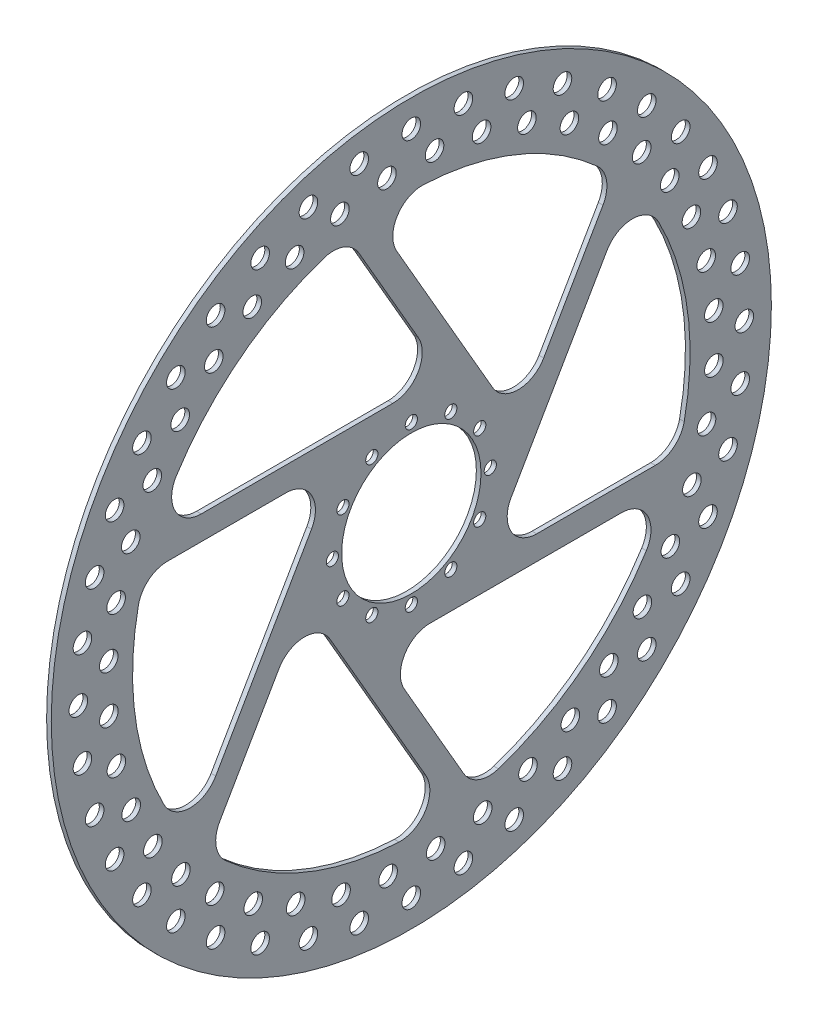
from build123d import *

# Parameters (mm, degrees)
SKETCH1_R           = 155
SKETCH1_R_2         = 4
SKETCH1_R_3         = 2.625
SKETCH1_R_4         = 30
BOSS_EXTRUDE1_DEPTH = 2
FILLET1_R           = 12.7


with BuildPart() as part:
    # Sketch1 → Boss-Extrude1 (new body)
    with BuildSketch(Plane(origin=(0, 0, 0), x_dir=(0, 0, -1), z_dir=(1, 0, 0))):
        Circle(SKETCH1_R)
        with BuildLine():
            Line((-27.462565886, 116.815270727), (14, 45))
            Line((14, 45), (-111.242977306, 45))
            ThreePointArc((-111.242977306, 45), (-78.097152352, 91.108917206), (-27.462565886, 116.815270727))
        make_face(mode=Mode.SUBTRACT)
        with BuildLine():
            Line((45.97114317, 10.375644347), (-16.650345483, 118.83924434))
            ThreePointArc((-16.650345483, 118.83924434), (39.854060636, 113.188576503), (87.433709056, 82.190915074))
            Line((87.433709056, 82.190915074), (45.97114317, 10.375644347))
        make_face(mode=Mode.SUBTRACT)
        with BuildLine():
            Line((31.97114317, -34.624355653), (94.592631824, 73.83924434))
            ThreePointArc((94.592631824, 73.83924434), (117.951212988, 22.079659297), (114.896274942, -34.624355653))
            Line((114.896274942, -34.624355653), (31.97114317, -34.624355653))
        make_face(mode=Mode.SUBTRACT)
        with BuildLine():
            Line((-14, -45), (111.242977306, -45))
            ThreePointArc((111.242977306, -45), (78.097152352, -91.108917206), (27.462565886, -116.815270727))
            Line((27.462565886, -116.815270727), (-14, -45))
        make_face(mode=Mode.SUBTRACT)
        with BuildLine():
            Line((-45.97114317, -10.375644347), (16.650345483, -118.83924434))
            ThreePointArc((16.650345483, -118.83924434), (-39.854060636, -113.188576503), (-87.433709056, -82.190915074))
            Line((-87.433709056, -82.190915074), (-45.97114317, -10.375644347))
        make_face(mode=Mode.SUBTRACT)
        with BuildLine():
            Line((-31.97114317, 34.624355653), (-94.592631824, -73.83924434))
            ThreePointArc((-94.592631824, -73.83924434), (-117.951212988, -22.079659297), (-114.896274942, 34.624355653))
            Line((-114.896274942, 34.624355653), (-31.97114317, 34.624355653))
        make_face(mode=Mode.SUBTRACT)
        with Locations((-101.35197197, -101.35197197)):
            Circle(SKETCH1_R_2, mode=Mode.SUBTRACT)
        with Locations((-84.249219495, -115.959102527)):
            Circle(SKETCH1_R_2, mode=Mode.SUBTRACT)
        with Locations((-84.643406638, -99.488638417)):
            Circle(SKETCH1_R_2, mode=Mode.SUBTRACT)
        with Locations((-115.959102527, -84.249219495)):
            Circle(SKETCH1_R_2, mode=Mode.SUBTRACT)
        with Locations((-99.164757773, -85.022622149)):
            Circle(SKETCH1_R_2, mode=Mode.SUBTRACT)
        with Locations((-44.29243586, -136.318100669)):
            Circle(SKETCH1_R_2, mode=Mode.SUBTRACT)
        with Locations((-65.071971629, -127.710935134)):
            Circle(SKETCH1_R_2, mode=Mode.SUBTRACT)
        with Locations((-49.756983427, -120.775568977)):
            Circle(SKETCH1_R_2, mode=Mode.SUBTRACT)
        with Locations((-22.422273322, -141.568662152)):
            Circle(SKETCH1_R_2, mode=Mode.SUBTRACT)
        with Locations((0, -143.333333333)):
            Circle(SKETCH1_R_2, mode=Mode.SUBTRACT)
        with Locations((-30.250930871, -127.072328391)):
            Circle(SKETCH1_R_2, mode=Mode.SUBTRACT)
        with Locations((-10, -130.240145352)):
            Circle(SKETCH1_R_2, mode=Mode.SUBTRACT)
        with Locations((-68.037853917, -111.504914223)):
            Circle(SKETCH1_R_2, mode=Mode.SUBTRACT)
        with Locations((-127.710935134, -65.071971629)):
            Circle(SKETCH1_R_2, mode=Mode.SUBTRACT)
        with Locations((-136.318100669, -44.29243586)):
            Circle(SKETCH1_R_2, mode=Mode.SUBTRACT)
        with Locations((-120.584724218, -50.217723433)):
            Circle(SKETCH1_R_2, mode=Mode.SUBTRACT)
        with Locations((-111.244343463, -68.463066751)):
            Circle(SKETCH1_R_2, mode=Mode.SUBTRACT)
        with Locations((-141.568662152, -22.422273322)):
            Circle(SKETCH1_R_2, mode=Mode.SUBTRACT)
        with Locations((-126.955908864, -30.735853101)):
            Circle(SKETCH1_R_2, mode=Mode.SUBTRACT)
        with Locations((-130.201017692, -10.497164059)):
            Circle(SKETCH1_R_2, mode=Mode.SUBTRACT)
        with Locations((22.422273322, -141.568662152)):
            Circle(SKETCH1_R_2, mode=Mode.SUBTRACT)
        with Locations((10.497164059, -130.201017692)):
            Circle(SKETCH1_R_2, mode=Mode.SUBTRACT)
        with Locations((30.735853101, -126.955908864)):
            Circle(SKETCH1_R_2, mode=Mode.SUBTRACT)
        with Locations((44.29243586, -136.318100669)):
            Circle(SKETCH1_R_2, mode=Mode.SUBTRACT)
        with Locations((50.217723433, -120.584724218)):
            Circle(SKETCH1_R_2, mode=Mode.SUBTRACT)
        with Locations((65.071971629, -127.710935134)):
            Circle(SKETCH1_R_2, mode=Mode.SUBTRACT)
        with Locations((68.463066751, -111.244343463)):
            Circle(SKETCH1_R_2, mode=Mode.SUBTRACT)
        with Locations((84.249219495, -115.959102527)):
            Circle(SKETCH1_R_2, mode=Mode.SUBTRACT)
        with Locations((85.022622149, -99.164757773)):
            Circle(SKETCH1_R_2, mode=Mode.SUBTRACT)
        with Locations((101.35197197, -101.35197197)):
            Circle(SKETCH1_R_2, mode=Mode.SUBTRACT)
        with Locations((99.488638417, -84.643406638)):
            Circle(SKETCH1_R_2, mode=Mode.SUBTRACT)
        with Locations((115.959102527, -84.249219495)):
            Circle(SKETCH1_R_2, mode=Mode.SUBTRACT)
        with Locations((111.504914223, -68.037853917)):
            Circle(SKETCH1_R_2, mode=Mode.SUBTRACT)
        with Locations((127.710935134, -65.071971629)):
            Circle(SKETCH1_R_2, mode=Mode.SUBTRACT)
        with Locations((120.775568977, -49.756983427)):
            Circle(SKETCH1_R_2, mode=Mode.SUBTRACT)
        with Locations((136.318100669, -44.29243586)):
            Circle(SKETCH1_R_2, mode=Mode.SUBTRACT)
        with Locations((127.072328391, -30.250930871)):
            Circle(SKETCH1_R_2, mode=Mode.SUBTRACT)
        with Locations((141.568662152, -22.422273322)):
            Circle(SKETCH1_R_2, mode=Mode.SUBTRACT)
        with Locations((130.240145352, -10)):
            Circle(SKETCH1_R_2, mode=Mode.SUBTRACT)
        with Locations((143.333333333, 0)):
            Circle(SKETCH1_R_2, mode=Mode.SUBTRACT)
        with Locations((-143.333333333, 0)):
            Circle(SKETCH1_R_2, mode=Mode.SUBTRACT)
        with Locations((-130.240145352, 10)):
            Circle(SKETCH1_R_2, mode=Mode.SUBTRACT)
        with Locations((-141.568662152, 22.422273322)):
            Circle(SKETCH1_R_2, mode=Mode.SUBTRACT)
        with Locations((-127.072328391, 30.250930871)):
            Circle(SKETCH1_R_2, mode=Mode.SUBTRACT)
        with Locations((-136.318100669, 44.29243586)):
            Circle(SKETCH1_R_2, mode=Mode.SUBTRACT)
        with Locations((-120.775568977, 49.756983427)):
            Circle(SKETCH1_R_2, mode=Mode.SUBTRACT)
        with Locations((-127.710935134, 65.071971629)):
            Circle(SKETCH1_R_2, mode=Mode.SUBTRACT)
        with Locations((-111.504914223, 68.037853917)):
            Circle(SKETCH1_R_2, mode=Mode.SUBTRACT)
        with Locations((-115.959102527, 84.249219495)):
            Circle(SKETCH1_R_2, mode=Mode.SUBTRACT)
        with Locations((-99.488638417, 84.643406638)):
            Circle(SKETCH1_R_2, mode=Mode.SUBTRACT)
        with Locations((-101.35197197, 101.35197197)):
            Circle(SKETCH1_R_2, mode=Mode.SUBTRACT)
        with Locations((-85.022622149, 99.164757773)):
            Circle(SKETCH1_R_2, mode=Mode.SUBTRACT)
        with Locations((-84.249219495, 115.959102527)):
            Circle(SKETCH1_R_2, mode=Mode.SUBTRACT)
        with Locations((-68.463066751, 111.244343463)):
            Circle(SKETCH1_R_2, mode=Mode.SUBTRACT)
        with Locations((-65.071971629, 127.710935134)):
            Circle(SKETCH1_R_2, mode=Mode.SUBTRACT)
        with Locations((-50.217723433, 120.584724218)):
            Circle(SKETCH1_R_2, mode=Mode.SUBTRACT)
        with Locations((-44.29243586, 136.318100669)):
            Circle(SKETCH1_R_2, mode=Mode.SUBTRACT)
        with Locations((-30.735853101, 126.955908864)):
            Circle(SKETCH1_R_2, mode=Mode.SUBTRACT)
        with Locations((-10.497164059, 130.201017692)):
            Circle(SKETCH1_R_2, mode=Mode.SUBTRACT)
        with Locations((-22.422273322, 141.568662152)):
            Circle(SKETCH1_R_2, mode=Mode.SUBTRACT)
        with Locations((44.29243586, 136.318100669)):
            Circle(SKETCH1_R_2, mode=Mode.SUBTRACT)
        with Locations((99.164757773, 85.022622149)):
            Circle(SKETCH1_R_2, mode=Mode.SUBTRACT)
        with Locations((115.959102527, 84.249219495)):
            Circle(SKETCH1_R_2, mode=Mode.SUBTRACT)
        with Locations((84.643406638, 99.488638417)):
            Circle(SKETCH1_R_2, mode=Mode.SUBTRACT)
        with Locations((84.249219495, 115.959102527)):
            Circle(SKETCH1_R_2, mode=Mode.SUBTRACT)
        with Locations((101.35197197, 101.35197197)):
            Circle(SKETCH1_R_2, mode=Mode.SUBTRACT)
        with Locations((130.201017692, 10.497164059)):
            Circle(SKETCH1_R_2, mode=Mode.SUBTRACT)
        with Locations((126.955908864, 30.735853101)):
            Circle(SKETCH1_R_2, mode=Mode.SUBTRACT)
        with Locations((141.568662152, 22.422273322)):
            Circle(SKETCH1_R_2, mode=Mode.SUBTRACT)
        with Locations((111.244343463, 68.463066751)):
            Circle(SKETCH1_R_2, mode=Mode.SUBTRACT)
        with Locations((120.584724218, 50.217723433)):
            Circle(SKETCH1_R_2, mode=Mode.SUBTRACT)
        with Locations((136.318100669, 44.29243586)):
            Circle(SKETCH1_R_2, mode=Mode.SUBTRACT)
        with Locations((127.710935134, 65.071971629)):
            Circle(SKETCH1_R_2, mode=Mode.SUBTRACT)
        with Locations((68.037853917, 111.504914223)):
            Circle(SKETCH1_R_2, mode=Mode.SUBTRACT)
        with Locations((10, 130.240145352)):
            Circle(SKETCH1_R_2, mode=Mode.SUBTRACT)
        with Locations((30.250930871, 127.072328391)):
            Circle(SKETCH1_R_2, mode=Mode.SUBTRACT)
        with Locations((0, 143.333333333)):
            Circle(SKETCH1_R_2, mode=Mode.SUBTRACT)
        with Locations((22.422273322, 141.568662152)):
            Circle(SKETCH1_R_2, mode=Mode.SUBTRACT)
        with Locations((49.756983427, 120.775568977)):
            Circle(SKETCH1_R_2, mode=Mode.SUBTRACT)
        with Locations((65.071971629, 127.710935134)):
            Circle(SKETCH1_R_2, mode=Mode.SUBTRACT)
        with Locations((17, 29.444863729)):
            Circle(SKETCH1_R_3, mode=Mode.SUBTRACT)
        with Locations((-17, -29.444863729)):
            Circle(SKETCH1_R_3, mode=Mode.SUBTRACT)
        with Locations((-29.444863729, -17)):
            Circle(SKETCH1_R_3, mode=Mode.SUBTRACT)
        with Locations((0, -34)):
            Circle(SKETCH1_R_3, mode=Mode.SUBTRACT)
        with Locations((17, -29.444863729)):
            Circle(SKETCH1_R_3, mode=Mode.SUBTRACT)
        with Locations((29.444863729, -17)):
            Circle(SKETCH1_R_3, mode=Mode.SUBTRACT)
        with Locations((-34, 0)):
            Circle(SKETCH1_R_3, mode=Mode.SUBTRACT)
        with Locations((-29.444863729, 17)):
            Circle(SKETCH1_R_3, mode=Mode.SUBTRACT)
        with Locations((-17, 29.444863729)):
            Circle(SKETCH1_R_3, mode=Mode.SUBTRACT)
        Circle(SKETCH1_R_4, mode=Mode.SUBTRACT)
        with Locations((34, 0)):
            Circle(SKETCH1_R_3, mode=Mode.SUBTRACT)
        with Locations((29.444863729, 17)):
            Circle(SKETCH1_R_3, mode=Mode.SUBTRACT)
        with Locations((0, 34)):
            Circle(SKETCH1_R_3, mode=Mode.SUBTRACT)
    extrude(amount=BOSS_EXTRUDE1_DEPTH)

    # Fillet1
    fillet1_edges = [part.edges().sort_by_distance(p)[0] for p in [
        (1, 10.375644347, -45.97114317),
        (1, 82.190915074, -87.433709056),
        (1, 118.83924434, 16.650345483),
        (1, 73.83924434, -94.592631824),
        (1, -34.624355653, -31.97114317),
        (1, -34.624355653, -114.896274942),
        (1, -45, -111.242977306),
        (1, -45, 14),
        (1, -116.815270727, -27.462565886),
        (1, -118.83924434, -16.650345483),
        (1, -10.375644347, 45.97114317),
        (1, -82.190915074, 87.433709056),
        (1, -73.83924434, 94.592631824),
        (1, 34.624355653, 31.97114317),
        (1, 34.624355653, 114.896274942),
        (1, 45, 111.242977306),
        (1, 45, -14),
        (1, 116.815270727, 27.462565886),
    ]]
    fillet(fillet1_edges, radius=FILLET1_R)


solid = part.part
